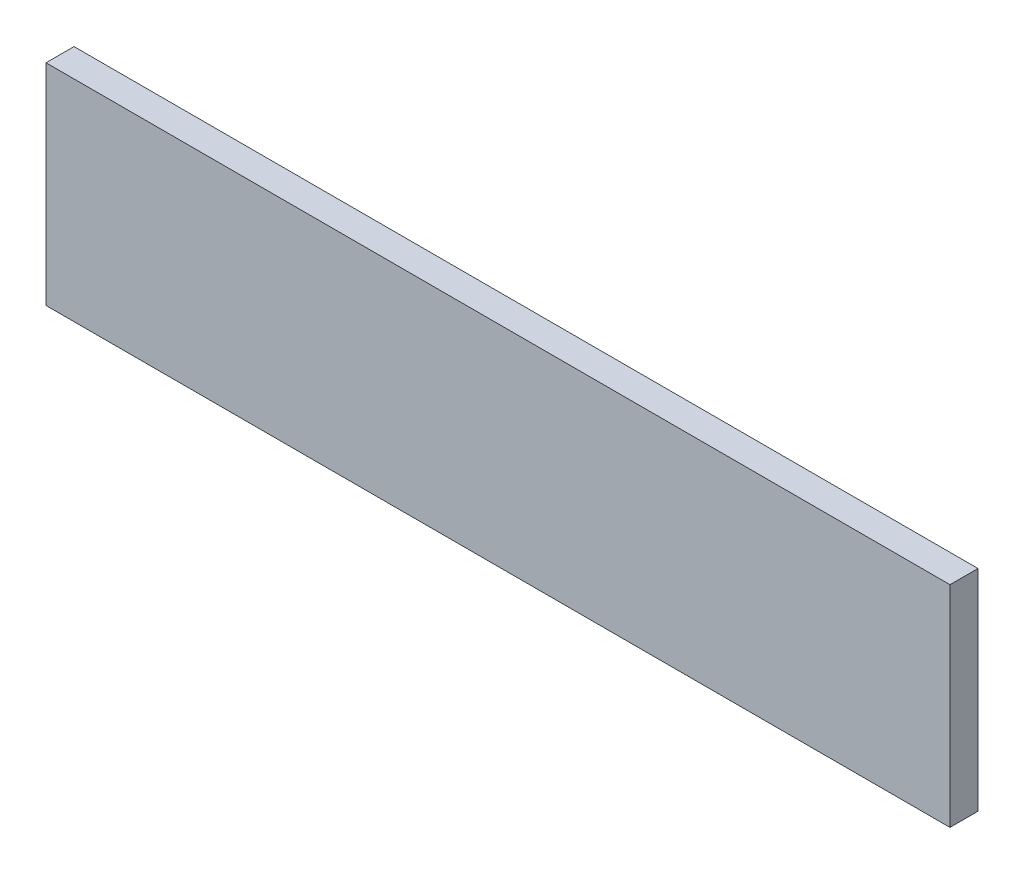
from build123d import *

# Parameters (mm, degrees)
CROQUIS1_W              = 645
CROQUIS1_H              = 150
SALIENTE_EXTRUIR1_DEPTH = 20


with BuildPart() as part:
    # Croquis1 → Saliente-Extruir1 (new body)
    with BuildSketch(Plane.XY):
        with Locations((-94.896530779, 64.479405034)):
            Rectangle(CROQUIS1_W, CROQUIS1_H)
    extrude(amount=SALIENTE_EXTRUIR1_DEPTH)


solid = part.part
